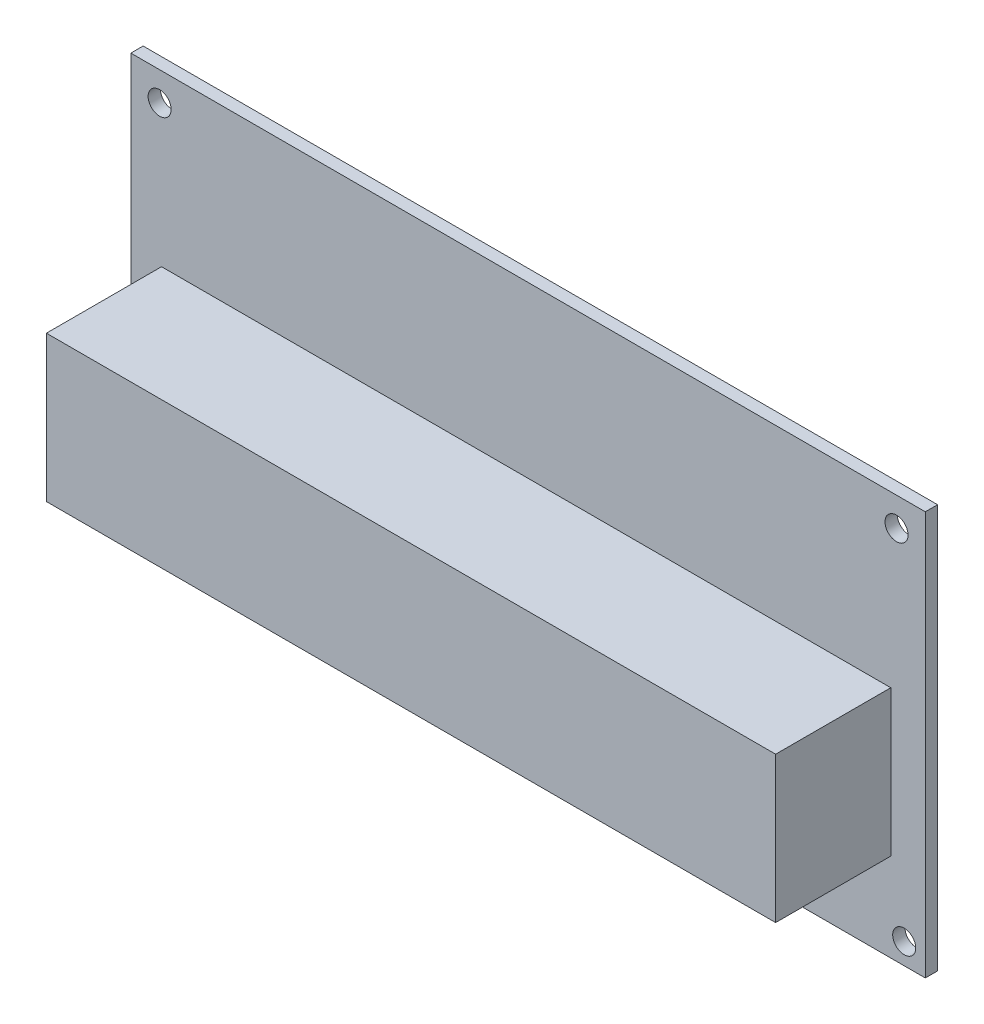
from build123d import *

# Parameters (mm, degrees)
ESQUISSE2_W        = 103.5
ESQUISSE2_H        = 52.6
ESQUISSE2_R        = 1.5
BOSS_EXTRU_1_DEPTH = 1.6
ESQUISSE3_W        = 95
ESQUISSE3_H        = 19
BOSS_EXTRU_2_DEPTH = 15


with BuildPart() as part:
    # Esquisse2 → Boss.-Extru.1 (new body)
    with BuildSketch(Plane.XY):
        Rectangle(ESQUISSE2_W, ESQUISSE2_H)
        with Locations((48, 22.55)):
            Circle(ESQUISSE2_R, mode=Mode.SUBTRACT)
        with Locations((49, -23.55)):
            Circle(ESQUISSE2_R, mode=Mode.SUBTRACT)
        with Locations((-49, -23.55)):
            Circle(ESQUISSE2_R, mode=Mode.SUBTRACT)
        with Locations((-48, 22.55)):
            Circle(ESQUISSE2_R, mode=Mode.SUBTRACT)
    extrude(amount=BOSS_EXTRU_1_DEPTH)

    # Esquisse3 → Boss.-Extru.2 (add)
    with BuildSketch(Plane.XY.offset(1.6)):
        with Locations((-0.25, -5.3)):
            Rectangle(ESQUISSE3_W, ESQUISSE3_H)
    extrude(amount=BOSS_EXTRU_2_DEPTH)


solid = part.part
